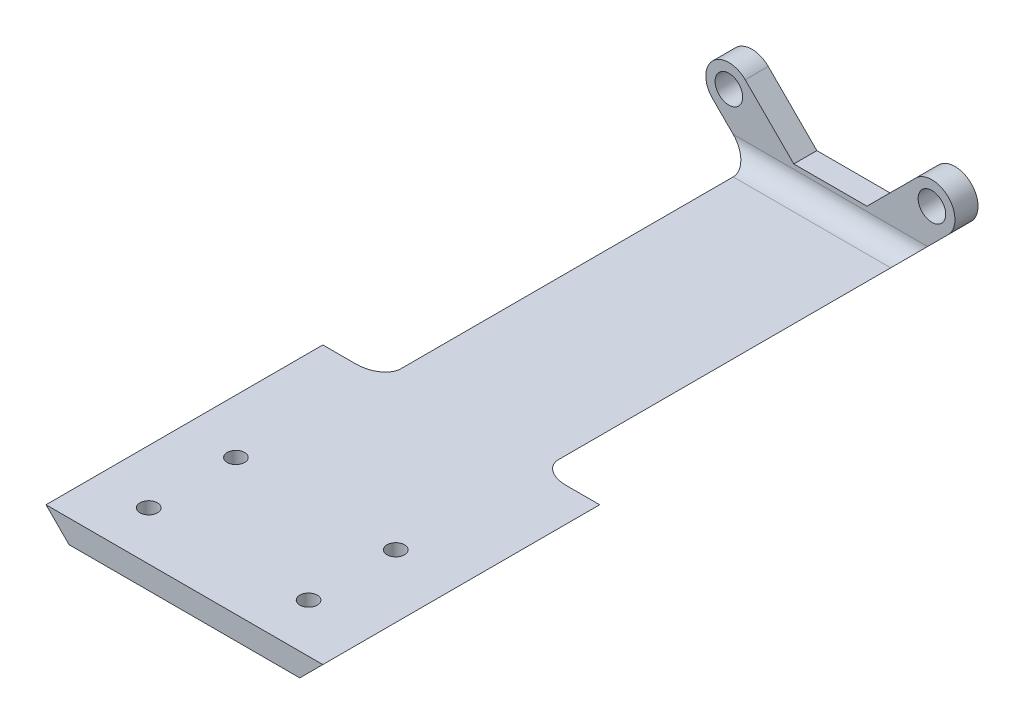
from build123d import *

# Parameters (mm, degrees)
BOSS_EXTRUDE1_DEPTH       = 3.175
SKETCH2_W                 = 15.330256122
SKETCH2_H                 = 3.175
BOSS_EXTRUDE2_DEPTH       = 50.8
FILLET1_R                 = 2.54
F_6_CLEARANCE_HOLE1_D     = 3.7973
F_6_CLEARANCE_HOLE1_DEPTH = 25.4
F_6_CLEARANCE_HOLE1_TIP   = 1.140824014
BOSS_EXTRUDE3_DEPTH       = 38.1
FILLET2_R                 = 2.54
M2_CLEARANCE_HOLE1_D      = 2.4
M2_CLEARANCE_HOLE1_DEPTH  = 25.4
M2_CLEARANCE_HOLE1_TIP    = 0.721032743


with BuildPart() as part:
    # Sketch1 → Boss-Extrude1 (new body)
    with BuildSketch(Plane.XY):
        with BuildLine():
            Line((-2.24506403, -2.24506403), (6.304871939, -10.795))
            Line((6.304871939, -10.795), (21.635128061, -10.795))
            Line((21.635128061, -10.795), (30.18506403, -2.24506403))
            ThreePointArc((30.18506403, -2.24506403), (30.18506403, 2.24506403), (25.69493597, 2.24506403))
            Line((25.69493597, 2.24506403), (19.004871939, -4.445))
            Line((19.004871939, -4.445), (8.935128061, -4.445))
            Line((8.935128061, -4.445), (2.24506403, 2.24506403))
            ThreePointArc((2.24506403, 2.24506403), (-2.24506403, 2.24506403), (-2.24506403, -2.24506403))
        make_face()
    extrude(amount=BOSS_EXTRUDE1_DEPTH)

    # Sketch2 → Boss-Extrude2 (add)
    with BuildSketch(Plane.XY.offset(3.175)):
        with Locations((13.97, -9.2075)):
            Rectangle(SKETCH2_W, SKETCH2_H)
        Polygon((3.129871939, -7.62), (6.304871939, -10.795), (6.304871939, -7.62), align=None)
        Polygon((21.635128061, -7.62), (21.635128061, -10.795), (24.810128061, -7.62), align=None)
    extrude(amount=BOSS_EXTRUDE2_DEPTH)

    # Fillet1
    fillet1_edges = [part.edges().sort_by_distance(p)[0] for p in [
        (13.97, -7.62, 3.175),
    ]]
    fillet(fillet1_edges, radius=FILLET1_R)

    # #6 Clearance Hole1
    with Locations(Plane(origin=(0, 0, 0), x_dir=(-1, 0, 0), z_dir=(0, 0, -1))):
        with Locations((-27.94, 0), (0, 0)):
            Hole(F_6_CLEARANCE_HOLE1_D / 2, depth=F_6_CLEARANCE_HOLE1_DEPTH)
            with Locations((0, 0, -(F_6_CLEARANCE_HOLE1_DEPTH + F_6_CLEARANCE_HOLE1_TIP / 2))):  # 118° drill point
                Cone(0, F_6_CLEARANCE_HOLE1_D / 2, F_6_CLEARANCE_HOLE1_TIP, mode=Mode.SUBTRACT)

    # Sketch7 → Boss-Extrude3 (add)
    with BuildSketch(Plane.XY.offset(53.975)):
        Polygon((-5.080004961, -7.62), (33.019995039, -7.62), (29.844995039, -10.795), (-1.905004961, -10.795), align=None)
    extrude(amount=BOSS_EXTRUDE3_DEPTH)

    # Fillet2
    fillet2_edges = [part.edges().sort_by_distance(p)[0] for p in [
        (4.717371939, -9.2075, 53.975),
        (23.222628061, -9.2075, 53.975),
    ]]
    fillet(fillet2_edges, radius=FILLET2_R)

    # M2 Clearance Hole1
    with Locations(Plane(origin=(0, -7.62, 0), x_dir=(-1, 0, 0), z_dir=(0, 1, 0))):
        with Locations((-2.354305281, 85.375), (-2.354305281, 73.375), (-24.354305281, 85.375), (-24.354305281, 73.375)):
            Hole(M2_CLEARANCE_HOLE1_D / 2, depth=M2_CLEARANCE_HOLE1_DEPTH)
            with Locations((0, 0, -(M2_CLEARANCE_HOLE1_DEPTH + M2_CLEARANCE_HOLE1_TIP / 2))):  # 118° drill point
                Cone(0, M2_CLEARANCE_HOLE1_D / 2, M2_CLEARANCE_HOLE1_TIP, mode=Mode.SUBTRACT)


solid = part.part
